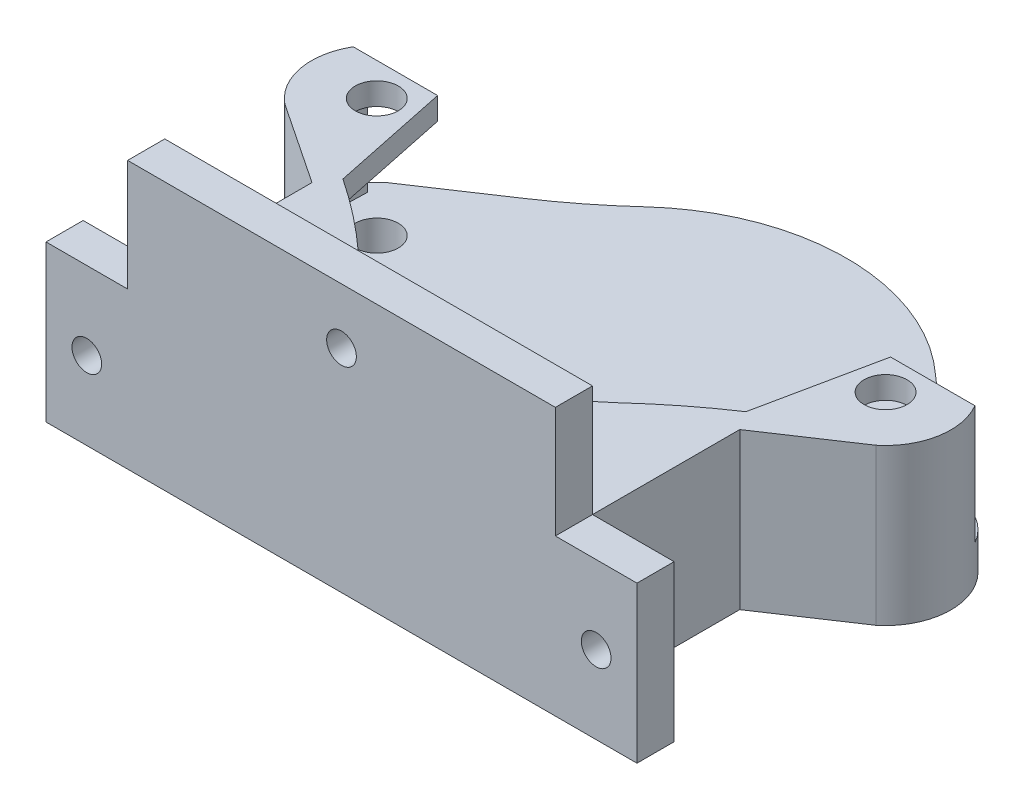
from build123d import *

# Parameters (mm, degrees)
SKETCH1_R           = 2.9
BOSS_EXTRUDE1_DEPTH = 5
BOSS_EXTRUDE2_DEPTH = 13
SKETCH4_R           = 2.9
BOSS_EXTRUDE3_DEPTH = 3
BOSS_EXTRUDE4_DEPTH = 21
SKETCH7_W           = 57.588234794
SKETCH7_H           = 15
SKETCH7_R           = 2
BOSS_EXTRUDE6_DEPTH = 5
SKETCH9_W           = 10.98683059
SKETCH9_H           = 21
SKETCH9_R           = 2
BOSS_EXTRUDE7_DEPTH = 5


with BuildPart() as part:
    # Sketch1 → Boss-Extrude1 (new body)
    with BuildSketch(Plane(origin=(0, 0, 0), x_dir=(1, 0, 0), z_dir=(0, 1, 0))):
        with BuildLine():
            Line((62.90038715, 19.069123632), (73.88721774, 26.399609553))
            ThreePointArc((73.88721774, 26.399609553), (77.156269753, 33.244214317), (73.88721774, 40.088819081))
            Line((73.88721774, 40.088819081), (62.90038715, 47.419305002))
            ThreePointArc((62.90038715, 47.419305002), (58.150415973, 50.856886947), (53.675790472, 54.645939921))
            ThreePointArc((53.675790472, 54.645939921), (34.106269753, 62.244214317), (14.536749034, 54.645939921))
            ThreePointArc((14.536749034, 54.645939921), (10.062123533, 50.856886947), (5.312152356, 47.419305002))
            Line((5.312152356, 47.419305002), (-5.674678234, 40.088819081))
            ThreePointArc((-5.674678234, 40.088819081), (-8.943730247, 33.244214317), (-5.674678234, 26.399609553))
            Line((-5.674678234, 26.399609553), (5.312152356, 19.069123632))
            ThreePointArc((5.312152356, 19.069123632), (10.062123533, 15.631541687), (14.536749034, 11.842488713))
            ThreePointArc((14.536749034, 11.842488713), (34.106269753, 4.244214317), (53.675790472, 11.842488713))
            ThreePointArc((53.675790472, 11.842488713), (58.150415973, 15.631541687), (62.90038715, 19.069123632))
        make_face()
        with Locations((68.356269753, 33.244214317)):
            Circle(SKETCH1_R, mode=Mode.SUBTRACT)
        with Locations((-0.143730247, 33.244214317)):
            Circle(SKETCH1_R, mode=Mode.SUBTRACT)
    extrude(amount=BOSS_EXTRUDE1_DEPTH)

    # Sketch3 → Boss-Extrude2 (add)
    with BuildSketch(Plane(origin=(0, 5, 0), x_dir=(1, 0, 0), z_dir=(0, 1, 0))):
        with BuildLine():
            Line((62.90038715, 19.069123632), (73.88721774, 26.399609553))
            ThreePointArc((73.88721774, 26.399609553), (77.011551697, 31.654845113), (75.9581291, 37.677242003))
            Line((75.9581291, 37.677242003), (74.027243913, 37.677242003))
            Line((74.027243913, 37.677242003), (74.156269753, 33.244214317))
            ThreePointArc((74.156269753, 33.244214317), (73.616142187, 30.800090348), (72.096358727, 28.811186631))
            Line((72.096358727, 28.811186631), (61.235353843, 21.564652451))
            ThreePointArc((61.235353843, 21.564652451), (56.300318854, 17.993138742), (51.651357294, 14.056460327))
            ThreePointArc((51.651357294, 14.056460327), (34.106269753, 7.244214317), (16.561182212, 14.056460327))
            ThreePointArc((16.561182212, 14.056460327), (11.912220652, 17.993138742), (6.977185663, 21.564652451))
            Line((6.977185663, 21.564652451), (-3.883819221, 28.811186631))
            ThreePointArc((-3.883819221, 28.811186631), (-5.403602681, 30.800090348), (-5.943730247, 33.244214317))
            Line((-5.943730247, 33.244214317), (-5.814704408, 37.677242003))
            Line((-5.814704408, 37.677242003), (-7.745589594, 37.677242003))
            ThreePointArc((-7.745589594, 37.677242003), (-8.799012191, 31.654845113), (-5.674678234, 26.399609553))
            Line((-5.674678234, 26.399609553), (5.312152356, 19.069123632))
            ThreePointArc((5.312152356, 19.069123632), (10.062123533, 15.631541687), (14.536749034, 11.842488713))
            ThreePointArc((14.536749034, 11.842488713), (34.106269753, 4.244214317), (53.675790472, 11.842488713))
            ThreePointArc((53.675790472, 11.842488713), (58.150415973, 15.631541687), (62.90038715, 19.069123632))
        make_face()
    extrude(amount=BOSS_EXTRUDE2_DEPTH)

    # Sketch4 → Boss-Extrude3 (add)
    with BuildSketch(Plane(origin=(0, 18, 0), x_dir=(1, 0, 0), z_dir=(0, 1, 0))):
        with BuildLine():
            Line((3.616180779, 37.677242003), (-7.745589594, 37.677242003))
            ThreePointArc((-7.745589594, 37.677242003), (-8.799012191, 31.654845113), (-5.674678234, 26.399609553))
            Line((-5.674678234, 26.399609553), (5.312152356, 19.069123632))
            ThreePointArc((5.312152356, 19.069123632), (10.062123533, 15.631541687), (14.536749034, 11.842488713))
            ThreePointArc((14.536749034, 11.842488713), (34.106269753, 4.244214317), (53.675790472, 11.842488713))
            ThreePointArc((53.675790472, 11.842488713), (58.150415973, 15.631541687), (62.90038715, 19.069123632))
            Line((62.90038715, 19.069123632), (73.88721774, 26.399609553))
            ThreePointArc((73.88721774, 26.399609553), (77.011551697, 31.654845113), (75.9581291, 37.677242003))
            Line((75.9581291, 37.677242003), (64.596358727, 37.677242003))
            Line((64.596358727, 37.677242003), (61.235353843, 21.564652451))
            ThreePointArc((61.235353843, 21.564652451), (56.300318854, 17.993138742), (51.651357294, 14.056460327))
            ThreePointArc((51.651357294, 14.056460327), (34.106269753, 7.244214317), (16.561182212, 14.056460327))
            ThreePointArc((16.561182212, 14.056460327), (11.912220652, 17.993138742), (6.977185663, 21.564652451))
            Line((6.977185663, 21.564652451), (3.616180779, 37.677242003))
        make_face()
        with Locations((-0.143730247, 33.244214317)):
            Circle(SKETCH4_R, mode=Mode.SUBTRACT)
        with Locations((68.356269753, 33.244214317)):
            Circle(SKETCH4_R, mode=Mode.SUBTRACT)
    extrude(amount=BOSS_EXTRUDE3_DEPTH)

    # Sketch5 → Boss-Extrude4 (add)
    with BuildSketch(Plane.XZ):
        with BuildLine():
            Line((62.90038715, -19.069123632), (62.90038715, 5.755785683))
            Line((62.90038715, 5.755785683), (5.312152356, 5.755785683))
            Line((5.312152356, 5.755785683), (5.312152356, -19.069123632))
            ThreePointArc((5.312152356, -19.069123632), (10.062123533, -15.631541687), (14.536749034, -11.842488713))
            ThreePointArc((14.536749034, -11.842488713), (34.106269753, -4.244214317), (53.675790472, -11.842488713))
            ThreePointArc((53.675790472, -11.842488713), (58.150415973, -15.631541687), (62.90038715, -19.069123632))
        make_face()
    extrude(amount=-BOSS_EXTRUDE4_DEPTH)

    # Sketch7 → Boss-Extrude6 (add)
    with BuildSketch(Plane.XY.offset(5.755785683)):
        with Locations((34.106269753, 28.5)):
            Rectangle(SKETCH7_W, SKETCH7_H)
        with Locations((34.106269753, 28.5)):
            Circle(SKETCH7_R, mode=Mode.SUBTRACT)
    extrude(amount=-BOSS_EXTRUDE6_DEPTH)

    # Sketch9 → Boss-Extrude7 (add)
    with BuildSketch(Plane.XY.offset(5.755785683)):
        with Locations((68.393802445, 10.5)):
            Rectangle(SKETCH9_W, SKETCH9_H)
        with Locations((68.393802445, 10.5)):
            Circle(SKETCH9_R, mode=Mode.SUBTRACT)
        with Locations((-0.181262939, 10.5)):
            Rectangle(SKETCH9_W, SKETCH9_H)
        with Locations((-0.181262939, 10.5)):
            Circle(SKETCH9_R, mode=Mode.SUBTRACT)
    extrude(amount=-BOSS_EXTRUDE7_DEPTH)


solid = part.part
